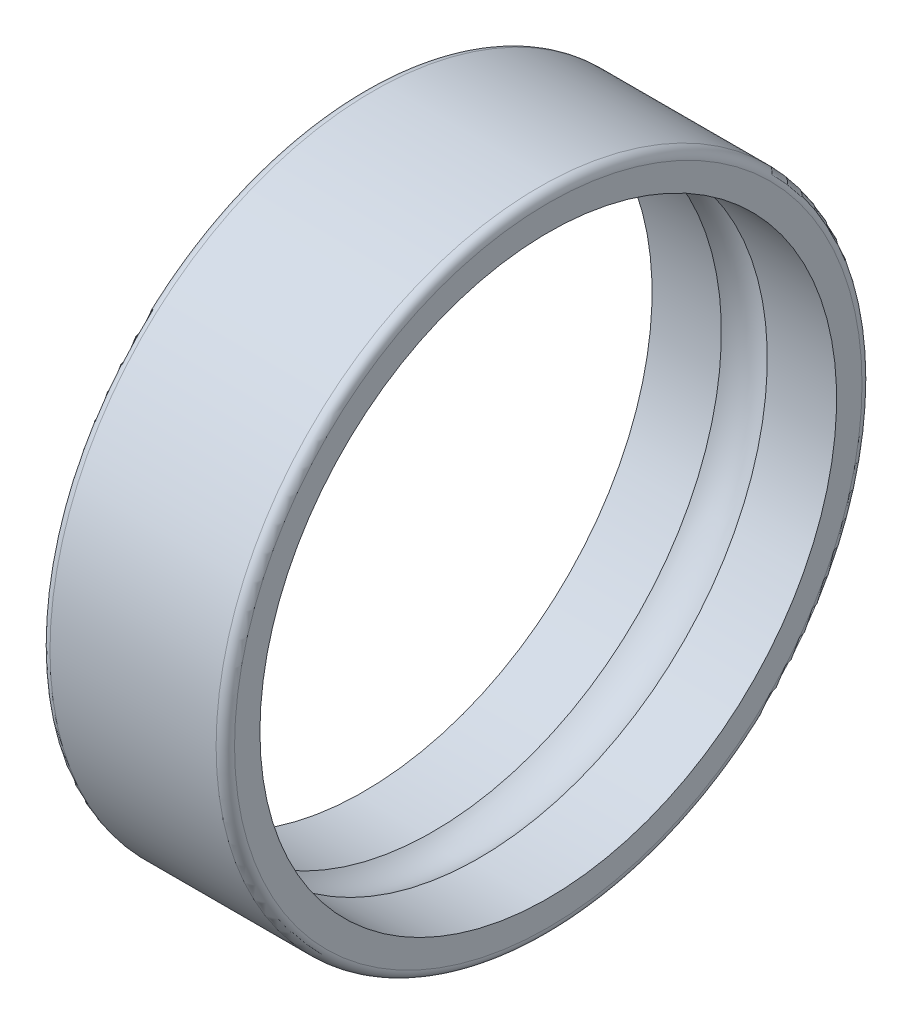
from build123d import *


with BuildPart() as part:
    # Sketch1 → Revolve1 (revolve)
    with BuildSketch(Plane.XY):
        with BuildLine():
            Line((0, 3.4), (0, 3.125))
            Line((0, 3.125), (0.751253141, 3.125))
            ThreePointArc((0.751253141, 3.125), (1, 3.2), (1.248746859, 3.125))
            Line((1.248746859, 3.125), (2, 3.125))
            Line((2, 3.125), (2, 3.4))
            ThreePointArc((2, 3.4), (1.970710678, 3.470710678), (1.9, 3.5))
            Line((1.9, 3.5), (0.1, 3.5))
            ThreePointArc((0.1, 3.5), (0.029289322, 3.470710678), (0, 3.4))
        make_face()
    revolve(axis=Axis((2, 0, 0), (-1, 0, 0)))


solid = part.part
